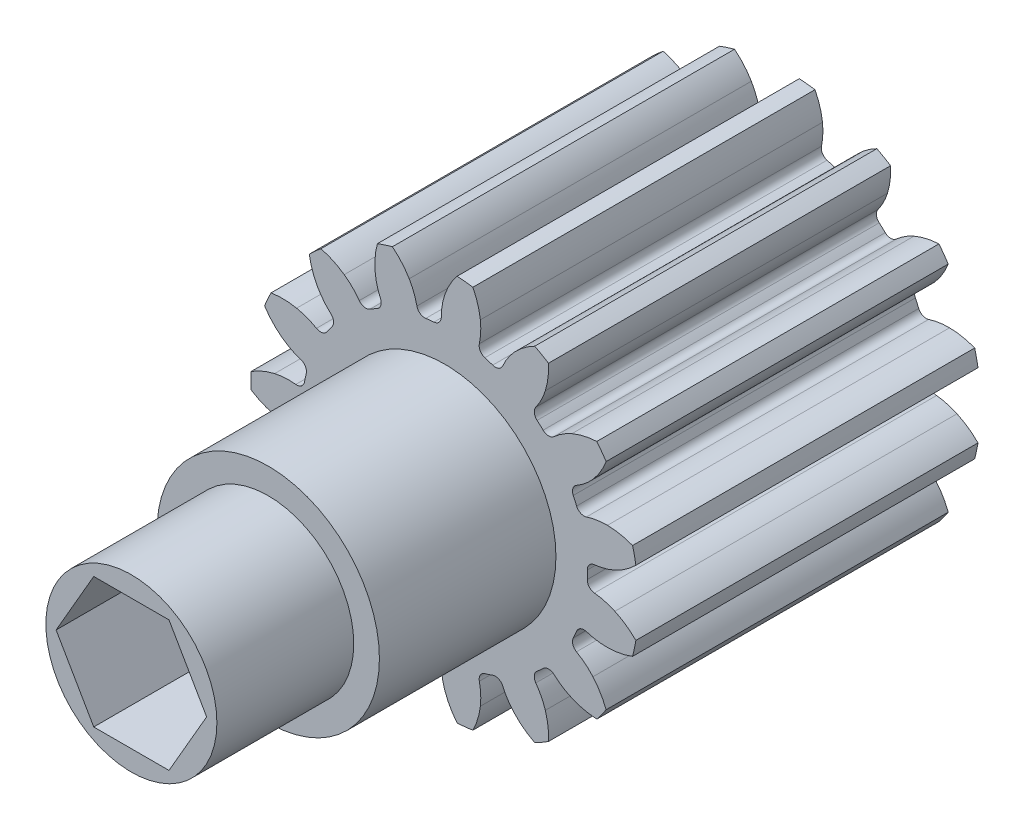
from build123d import *

# Parameters (mm, degrees)
SKETCH1_R            = 7.196666667
ROUND_STOCK_DEPTH    = 6.35
SINGLE_TOOTH_DEPTH   = 13.7
TOOTH_PATTERN_COUNT  = 15
SKETCH4_R            = 3.175
TOPBEARINGBOSS_DEPTH = 11.6332
SKETCH5_R            = 2.41935
ROUNDBORE_DEPTH      = 18.9832
ROUNDBORE_DEPTH_BACK = 7.35
HEX_2_DEPTH          = 18.9832
HEX_2_DEPTH_BACK     = 7.35
SKETCH8_R            = 4.1275
SKETCH8_R_2          = 3.175
BOSS_EXTRUDE1_DEPTH  = 6.5532
SKETCH9_R            = 1.778
BOSS_EXTRUDE2_DEPTH  = 3.175


with BuildPart() as part:
    # Sketch1 → Round Stock (new body, symmetric)
    with BuildSketch(Plane.XY):
        Circle(SKETCH1_R)
    extrude(amount=ROUND_STOCK_DEPTH, both=True)

    # Sketch2 → Single Tooth (cut, through all)
    with BuildSketch(Plane.XY.offset(6.35)):
        with BuildLine():
            ThreePointArc((-6.68842664, -2.656493967), (-7.039402233, -1.496271135), (-7.190675214, -0.293600202))
            ThreePointArc((-7.190675214, -0.293600202), (-6.769612211, -0.518778621), (-6.315077167, -0.665056667))
            ThreePointArc((-6.315077167, -0.665056667), (-5.923784873, -0.719884978), (-5.528796647, -0.709879736))
            ThreePointArc((-5.528796647, -0.709879736), (-5.319713161, -0.76702948), (-5.20546795, -0.951230536))
            ThreePointArc((-5.20546795, -0.951230536), (-5.176031054, -1.100199364), (-5.142331916, -1.248262225))
            ThreePointArc((-5.142331916, -1.248262225), (-5.17177879, -1.463005976), (-5.339541164, -1.60025678))
            ThreePointArc((-5.339541164, -1.60025678), (-5.704450362, -1.751772721), (-6.039612977, -1.961013791))
            ThreePointArc((-6.039612977, -1.961013791), (-6.39535476, -2.279521493), (-6.68842664, -2.656493967))
        make_face()
    single_tooth = extrude(amount=-SINGLE_TOOTH_DEPTH, mode=Mode.SUBTRACT)

    # Tooth Pattern: Single Tooth ×15 about axis
    tooth_pattern_axis = Axis((0, 0, 0), (0, 0, 1))
    for i in range(1, TOOTH_PATTERN_COUNT):
        add(single_tooth.rotate(tooth_pattern_axis, i * 360 / TOOTH_PATTERN_COUNT), mode=Mode.SUBTRACT)

    # Sketch4 → TopBearingBoss (add)
    with BuildSketch(Plane.XY.offset(6.35)):
        Circle(SKETCH4_R)
    extrude(amount=TOPBEARINGBOSS_DEPTH)

    # Sketch5 → RoundBore (cut, two sides)
    with BuildSketch(Plane.XY) as roundbore_sk:
        Circle(SKETCH5_R)
    extrude(amount=ROUNDBORE_DEPTH, mode=Mode.SUBTRACT)
    extrude(roundbore_sk.sketch, amount=-ROUNDBORE_DEPTH_BACK, mode=Mode.SUBTRACT)

    # Sketch6 → Hex 2 (cut, two sides)
    with BuildSketch(Plane.XY) as hex_2_sk:
        Polygon((1.396812374, 2.41935), (-1.396812374, 2.41935), (-2.793624748, 0), (-1.396812374, -2.41935), (1.396812374, -2.41935), (2.793624748, 0), align=None)
    extrude(amount=HEX_2_DEPTH, mode=Mode.SUBTRACT)
    extrude(hex_2_sk.sketch, amount=-HEX_2_DEPTH_BACK, mode=Mode.SUBTRACT)

    # Sketch8 → Boss-Extrude1 (add)
    with BuildSketch(Plane.XY.offset(6.35)):
        Circle(SKETCH8_R)
        Circle(SKETCH8_R_2, mode=Mode.SUBTRACT)
    extrude(amount=BOSS_EXTRUDE1_DEPTH)

    # Sketch9 → Boss-Extrude2 (add)
    with BuildSketch(Plane(origin=(0, 0, -6.35), x_dir=(-1, 0, 0), z_dir=(0, 0, -1))):
        Polygon((1.396812374, -2.41935), (2.793624748, 0), (1.396812374, 2.41935), (-1.396812374, 2.41935), (-2.793624748, 0), (-1.396812374, -2.41935), align=None)
        Circle(SKETCH9_R, mode=Mode.SUBTRACT)
    extrude(amount=-BOSS_EXTRUDE2_DEPTH)


solid = part.part
